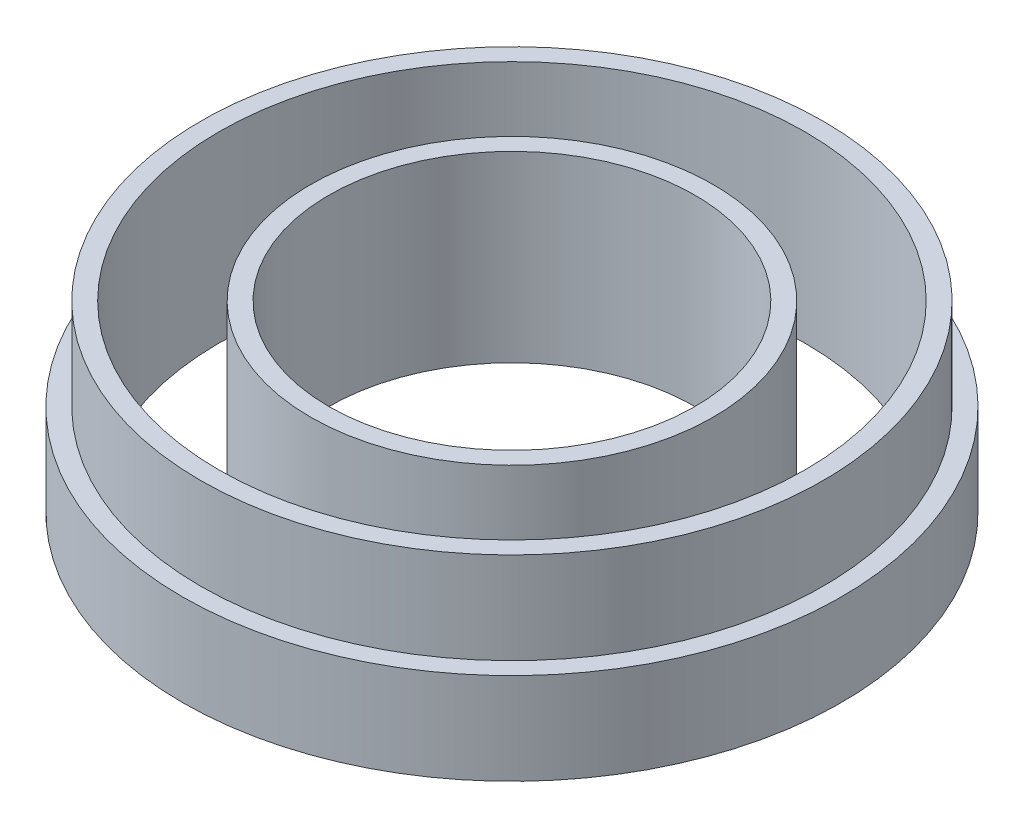
from build123d import *

# Parameters (mm, degrees)
SKETCH1_R             = 5.5
SKETCH1_R_2           = 5
BOSS_EXTRUDE1_DEPTH   = 5
SKETCH1_R_3           = 8.5
SKETCH1_R_4           = 8
BOSS_EXTRUDE1_2_DEPTH = 5
SKETCH2_R             = 9
SKETCH2_R_2           = 8.5
BOSS_EXTRUDE3_DEPTH   = 2.5


with BuildPart() as part:
    # Sketch1 → Boss-Extrude1 (new body)
    with BuildSketch(Plane(origin=(0, 0, 0), x_dir=(1, 0, 0), z_dir=(0, 1, 0))):
        Circle(SKETCH1_R)
        Circle(SKETCH1_R_2, mode=Mode.SUBTRACT)
    extrude(amount=BOSS_EXTRUDE1_DEPTH)


with BuildPart() as body_2:
    # Sketch1 → Boss-Extrude1 2 (new body)
    with BuildSketch(Plane(origin=(0, 0, 0), x_dir=(1, 0, 0), z_dir=(0, 1, 0))):
        Circle(SKETCH1_R_3)
        Circle(SKETCH1_R_4, mode=Mode.SUBTRACT)
    extrude(amount=BOSS_EXTRUDE1_2_DEPTH)

    # Sketch2 → Boss-Extrude3 (add)
    with BuildSketch(Plane(origin=(0, 0, 0), x_dir=(1, 0, 0), z_dir=(0, 1, 0))):
        Circle(SKETCH2_R)
        Circle(SKETCH2_R_2, mode=Mode.SUBTRACT)
    extrude(amount=BOSS_EXTRUDE3_DEPTH)


solid = Compound([part.part, body_2.part])
